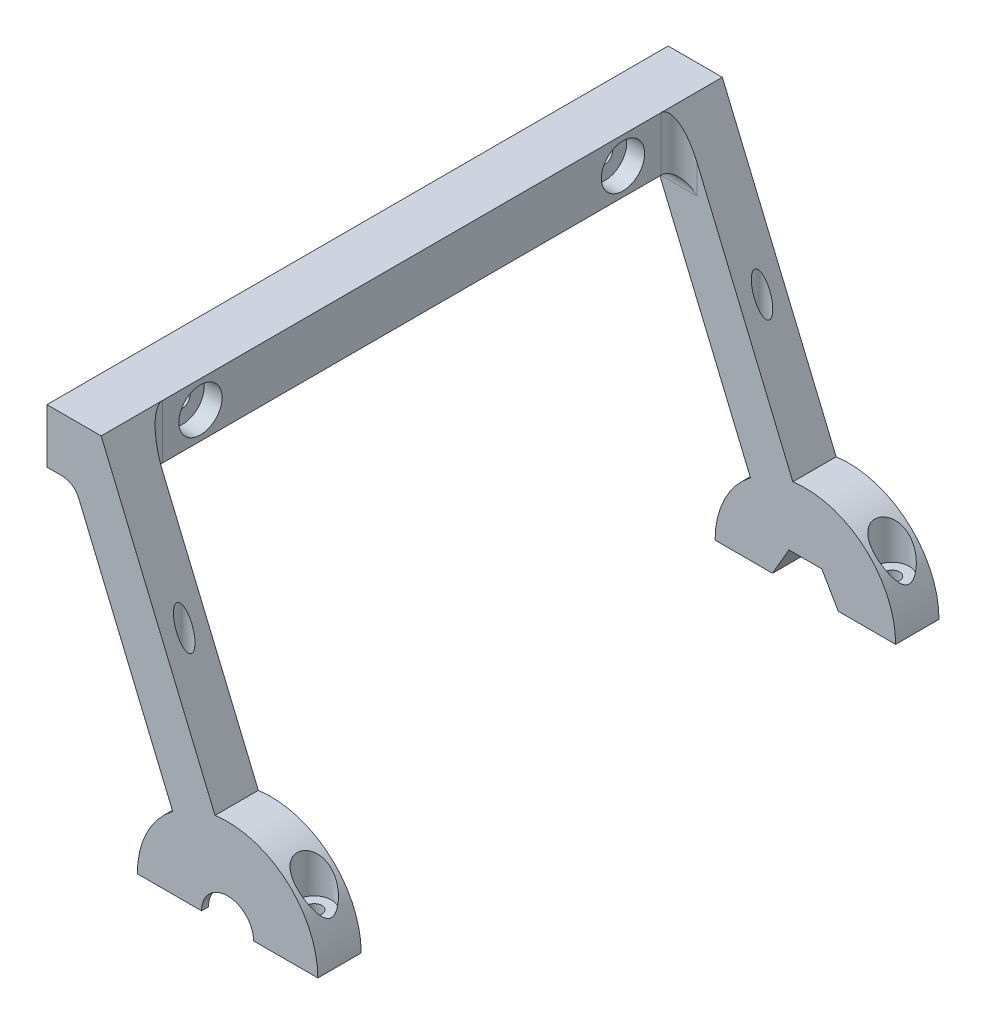
from build123d import *

# Parameters (mm, degrees)
SKETCH1_W               = 15
SKETCH1_H               = 15
BOSS_EXTRUDE1_DEPTH     = 86
BOSS_EXTRUDE2_DEPTH     = 12
SKETCH3_R               = 6
CUT_EXTRUDE1_DEPTH      = 5
SKETCH4_R               = 2.1
CUT_EXTRUDE2_DEPTH      = 135.726016512
BOSS_EXTRUDE5_DEPTH     = 12
SKETCH8_R               = 4.75
CUT_EXTRUDE4_DEPTH      = 4
CUT_EXTRUDE4_DEPTH_BACK = 10
SKETCH6_R               = 2.1
CUT_EXTRUDE5_DEPTH      = 149.162917192
FILLET1_R               = 5
CUT_EXTRUDE6_REACH      = 208.631
SKETCH9_R               = 7.2
CUT_EXTRUDE7_START      = -1.925
SKETCH10_R              = 13.1
CUT_EXTRUDE7_DEPTH      = 8.15
CUT_EXTRUDE8_REACH      = 208.631


with BuildPart() as part:
    # Sketch1 → Boss-Extrude1 (new body)
    with BuildSketch(Plane.XY):
        Rectangle(SKETCH1_W, SKETCH1_H)
    extrude(amount=BOSS_EXTRUDE1_DEPTH)

    # Sketch2 → Boss-Extrude2 (add)
    with BuildSketch(Plane.XY.offset(86)):
        Polygon((7.5, 7.5), (49.391891892, -92.5), (35.608108108, -92.5), (0, -7.5), align=None)
    extrude(amount=-BOSS_EXTRUDE2_DEPTH)

    # Sketch3 → Cut-Extrude1 (cut)
    with BuildSketch(Plane(origin=(7.5, 0, 0), x_dir=(0, 0, -1), z_dir=(1, 0, 0))):
        with Locations((-58.5, 0)):
            Circle(SKETCH3_R)
    extrude(amount=-CUT_EXTRUDE1_DEPTH, mode=Mode.SUBTRACT)

    # Sketch4 → Cut-Extrude2 (cut, through all)
    with BuildSketch(Plane(origin=(2.5, 0, 0), x_dir=(0, 0, -1), z_dir=(1, 0, 0))):
        with Locations((-58.5, 0)):
            Circle(SKETCH4_R)
    extrude(amount=-CUT_EXTRUDE2_DEPTH, mode=Mode.SUBTRACT)

    # Sketch5 → Boss-Extrude5 (add)
    with BuildSketch(Plane.XY.offset(86)):
        with BuildLine():
            Line((17.5, -92.5), (67.5, -92.5))
            ThreePointArc((67.5, -92.5), (42.5, -67.5), (17.5, -92.5))
        make_face()
    extrude(amount=-BOSS_EXTRUDE5_DEPTH)

    # Sketch8 → Cut-Extrude4 (cut, two sides)
    with BuildSketch(Plane(origin=(0, -72.655502084, 0), x_dir=(1, 0, 0), z_dir=(0, 1, 0))) as cut_extrude4_sk:
        with Locations(Location((24.5, -80, 0), (0, 0, 76.371804965))):
            Circle(SKETCH8_R)
        with Locations(Location((60.5, -80, 0), (0, 0, 90))):
            Circle(SKETCH8_R)
    extrude(amount=CUT_EXTRUDE4_DEPTH, mode=Mode.SUBTRACT)
    extrude(cut_extrude4_sk.sketch, amount=-CUT_EXTRUDE4_DEPTH_BACK, mode=Mode.SUBTRACT)

    # Sketch6 → Cut-Extrude5 (cut, through all)
    with BuildSketch(Plane.XZ.offset(92.5)):
        with Locations(Location((24.5, 80, 0), (0, 0, 270))):
            Circle(SKETCH6_R)
        with Locations(Location((60.5, 80, 0), (0, 0, 90))):
            Circle(SKETCH6_R)
    extrude(amount=-CUT_EXTRUDE5_DEPTH, mode=Mode.SUBTRACT)

    # Fillet1
    fillet1_edges = [part.edges().sort_by_distance(p)[0] for p in [
        (3.75, -7.5, 74),
        (7.5, 0, 74),
        (0, -7.5, 80),
    ]]
    fillet(fillet1_edges, radius=FILLET1_R)

    # Mirror2: part across plane


with BuildPart() as part_1:
    add(part.part)
    add(part.part.mirror(Plane(origin=(0, 0, 0), x_dir=(1, 0, 0), z_dir=(0, 0, -1))))

    # Sketch9 → Cut-Extrude6 (cut, up to next)
    with BuildSketch(Plane.XY.offset(86), mode=Mode.PRIVATE) as cut_extrude6_sk1:
        with Locations((42.5, -92.5)):
            Circle(SKETCH9_R)
    cut_extrude6_tool1 = extrude(cut_extrude6_sk1.sketch, amount=-CUT_EXTRUDE6_REACH, mode=Mode.PRIVATE) & part_1.part
    add(cut_extrude6_tool1.solids().sort_by_distance((42.5, -92.5, 86))[0], mode=Mode.SUBTRACT)

    # Sketch10 → Cut-Extrude7 (cut)
    with BuildSketch(Plane.XY.offset(86).offset(CUT_EXTRUDE7_START)):
        with Locations((42.5, -92.5)):
            Circle(SKETCH10_R)
    extrude(amount=-CUT_EXTRUDE7_DEPTH, mode=Mode.SUBTRACT)

    # Sketch11 → Cut-Extrude8 (cut, up to next)
    with BuildSketch(Plane(origin=(0, 0, -86), x_dir=(-1, 0, 0), z_dir=(0, 0, -1)), mode=Mode.PRIVATE) as cut_extrude8_sk1:
        Polygon((-33.4, -92.5), (-37.95, -84.619168826), (-47.05, -84.619168826), (-51.6, -92.5), (-47.05, -100.380831174), (-37.95, -100.380831174), align=None)
    cut_extrude8_tool1 = extrude(cut_extrude8_sk1.sketch, amount=-CUT_EXTRUDE8_REACH, mode=Mode.PRIVATE) & part_1.part
    add(cut_extrude8_tool1.solids().sort_by_distance((42.5, -92.5, -86))[0], mode=Mode.SUBTRACT)


solid = part_1.part
